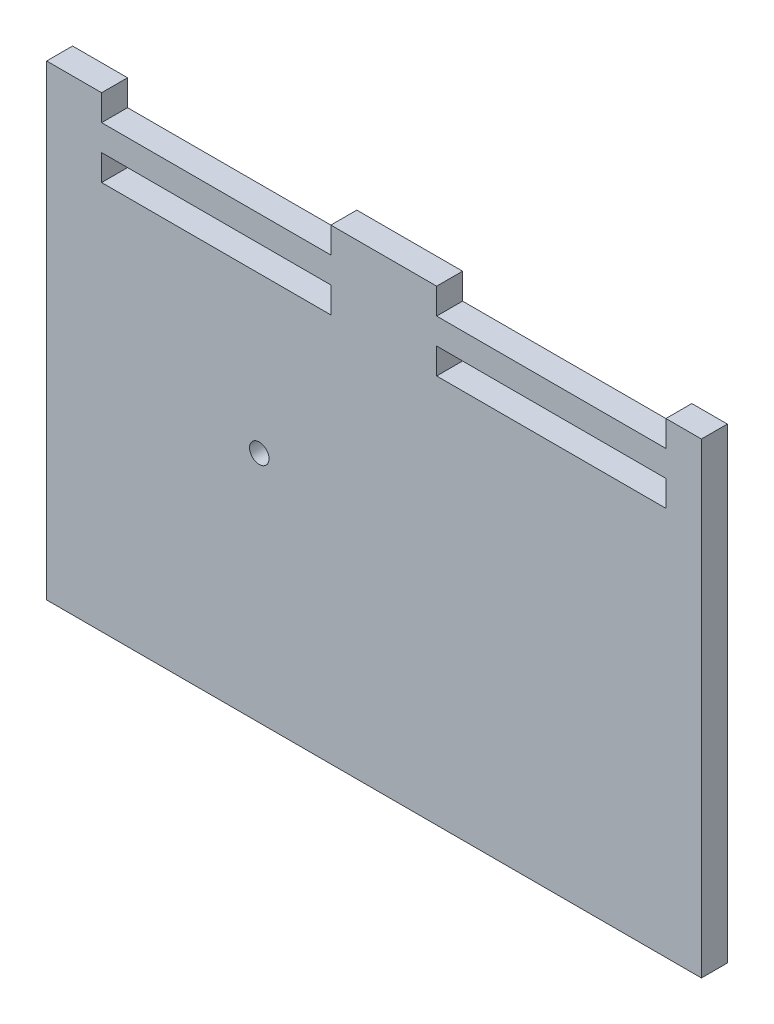
from build123d import *

# Parameters (mm, degrees)
SKETCH1_W           = 304.8
SKETCH1_H           = 228.6
BOSS_EXTRUDE1_DEPTH = 12.7
SKETCH2_R           = 4.7625
CUT_EXTRUDE1_DEPTH  = 12.7
SKETCH7_W           = 112.268
SKETCH7_H           = 12.7
CUT_EXTRUDE2_DEPTH  = 12.7
SKETCH8_W           = 12.7
SKETCH8_H           = 228.6
SKETCH8_W_2         = 3.175
BOSS_EXTRUDE2_DEPTH = 12.7


with BuildPart() as part:
    # Sketch1 → Boss-Extrude1 (new body)
    with BuildSketch(Plane.XY):
        with Locations((152.4, 114.3)):
            Rectangle(SKETCH1_W, SKETCH1_H)
    extrude(amount=BOSS_EXTRUDE1_DEPTH)

    # Sketch2 → Cut-Extrude1 (cut)
    with BuildSketch(Plane.XY.offset(12.7)):
        with Locations((91.44, 114.3)):
            Circle(SKETCH2_R)
    extrude(amount=-CUT_EXTRUDE1_DEPTH, mode=Mode.SUBTRACT)

    # Sketch7 → Cut-Extrude2 (cut)
    with BuildSketch(Plane.XY.offset(12.7)):
        with Locations((70.358, 222.25)):
            Rectangle(SKETCH7_W, SKETCH7_H)
        with Locations((234.442, 222.25)):
            Rectangle(SKETCH7_W, SKETCH7_H)
        with Locations((70.358, 196.85)):
            Rectangle(SKETCH7_W, SKETCH7_H)
        with Locations((234.442, 196.85)):
            Rectangle(SKETCH7_W, SKETCH7_H)
    extrude(amount=-CUT_EXTRUDE2_DEPTH, mode=Mode.SUBTRACT)

    # Sketch8 → Boss-Extrude2 (add)
    with BuildSketch(Plane.XY.offset(12.7)):
        with Locations((-6.35, 114.3)):
            Rectangle(SKETCH8_W, SKETCH8_H)
        with Locations((306.3875, 114.3)):
            Rectangle(SKETCH8_W_2, SKETCH8_H)
    extrude(amount=-BOSS_EXTRUDE2_DEPTH)


solid = part.part
